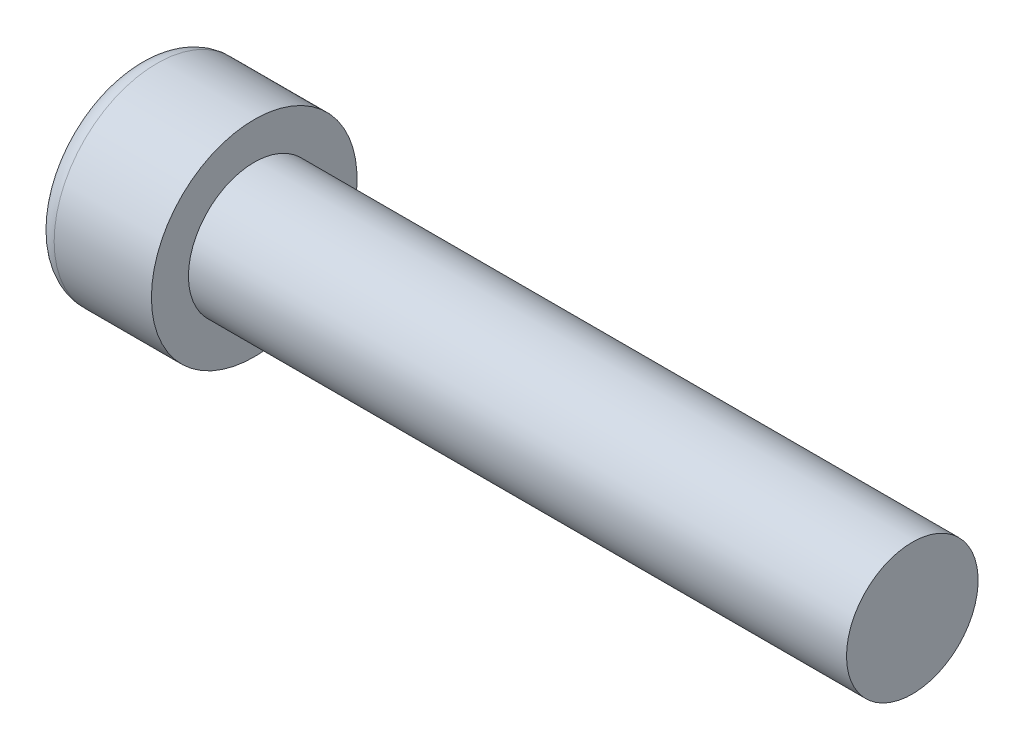
from build123d import *

# Parameters (mm, degrees)
SKETCH3_W         = 0.48
SKETCH3_H         = 1.82
SKETCH4_W         = 0.24
SKETCH4_H         = 0.24
CIRPATTERN1_COUNT = 2
CIRPATTERN1_ANGLE = 90


with BuildPart() as part:
    # BodySke → Base-Revolve (revolve)
    with BuildSketch(Plane.XY):
        with BuildLine():
            Line((1.6, 0.8), (1.6, 1.25))
            Line((1.6, 1.25), (0.417644882, 1.25))
            ThreePointArc((0.417644882, 1.25), (0.279902467, 1.206537597), (0.192048522, 1.091891892))
            ThreePointArc((0.192048522, 1.091891892), (0.04837782, 0.554326289), (0, 0))
            Line((0, 0), (9.6, 0))
            Line((9.6, 0), (9.6, 0.8))
            Line((9.6, 0.8), (1.6, 0.8))
        make_face()
    revolve(axis=Axis((-25.4, 0, 0), (1, 0, 0)))

    # Sketch3 → Cut-Loft1 section 0
    with BuildSketch(Plane(origin=(0, 0, 0), x_dir=(0, 0, -1), z_dir=(1, 0, 0))):
        Rectangle(SKETCH3_W, SKETCH3_H)
    # Sketch4 → Cut-Loft1 section 1
    with BuildSketch(Plane(origin=(1.19, 0, 0), x_dir=(0, 0, -1), z_dir=(1, 0, 0))):
        Rectangle(SKETCH4_W, SKETCH4_H)
    cut_loft1 = loft(mode=Mode.SUBTRACT)

    # CirPattern1: Cut-Loft1 ×2 about axis
    cirpattern1_axis = Axis((0, 0, 0), (1, 0, 0))
    for i in range(1, CIRPATTERN1_COUNT):
        add(cut_loft1.rotate(cirpattern1_axis, i * CIRPATTERN1_ANGLE / (CIRPATTERN1_COUNT - 1)), mode=Mode.SUBTRACT)


solid = part.part
